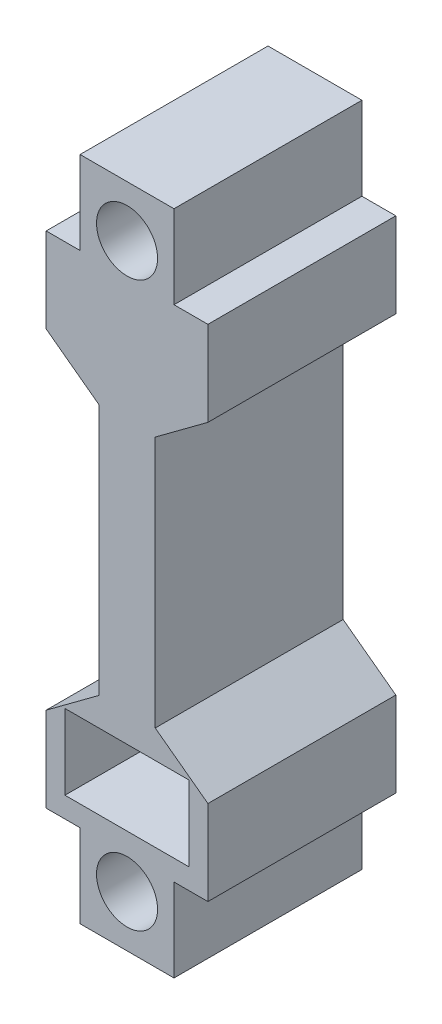
from build123d import *

# Parameters (mm, degrees)
SKETCH1_R           = 3.25
SKETCH1_W           = 13.214189082
SKETCH1_H           = 8
BOSS_EXTRUDE1_DEPTH = 20


with BuildPart() as part:
    # Sketch1 → Boss-Extrude1 (new body)
    with BuildSketch(Plane.XY):
        Polygon((-8.607094541, 26.60278493), (-4.998098652, 26.60278493), (-4.998098652, 35.452037516), (4.998098652, 35.452037516), (4.998098652, 26.60278493), (8.607094541, 26.60278493), (8.607094541, 17.567007114), (3, 13.408376353), (3, -13.408376353), (8.607094541, -17.567007114), (8.607094541, -26.60278493), (4.998098652, -26.60278493), (4.998098652, -35.452037516), (-4.998098652, -35.452037516), (-4.998098652, -26.60278493), (-8.607094541, -26.60278493), (-8.607094541, -17.567007114), (-3, -13.408376353), (-3, 13.408376353), (-8.607094541, 17.567007114), align=None)
        with Locations((0, 30)):
            Circle(SKETCH1_R, mode=Mode.SUBTRACT)
        with Locations((0, -30)):
            Circle(SKETCH1_R, mode=Mode.SUBTRACT)
        with Locations((0, -20.408376353)):
            Rectangle(SKETCH1_W, SKETCH1_H, mode=Mode.SUBTRACT)
    extrude(amount=BOSS_EXTRUDE1_DEPTH)


solid = part.part
